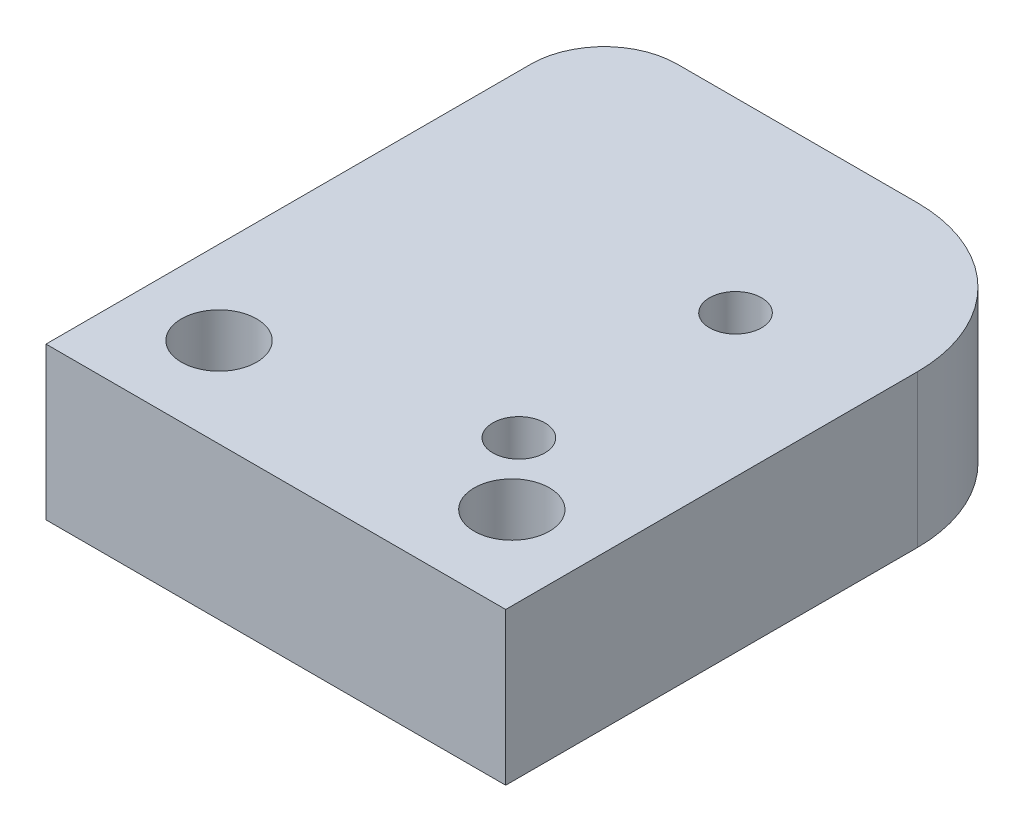
from build123d import *

# Parameters (mm, degrees)
SKETCH1_W                                           = 19.939
SKETCH1_H                                           = 24.2062
BOSS_EXTRUDE1_DEPTH                                 = 6.604
F_4_40_TAPPED_HOLE1_D                               = 2.2606
F_4_40_TAPPED_HOLE1_DEPTH                           = 6.604
CBORE_FOR_4_BINDING_HEAD_MACHINE_SCREW3_D           = 3.2639
CBORE_FOR_4_BINDING_HEAD_MACHINE_SCREW3_CBORE_D     = 4.9022
CBORE_FOR_4_BINDING_HEAD_MACHINE_SCREW3_CBORE_DEPTH = 1.7272
FILLET1_R                                           = 6.35
FILLET2_R                                           = 3.175


with BuildPart() as part:
    # Sketch1 → Boss-Extrude1 (new body)
    with BuildSketch(Plane(origin=(0, 0, 0), x_dir=(1, 0, 0), z_dir=(0, 1, 0))):
        with Locations((0, 12.1031)):
            Rectangle(SKETCH1_W, SKETCH1_H)
    extrude(amount=BOSS_EXTRUDE1_DEPTH)

    # #4-40 Tapped Hole1
    with Locations(Plane(origin=(0, 6.604, 0), x_dir=(1, 0, 0), z_dir=(0, 1, 0))):
        with Locations((3.81, 16.129), (3.81, 6.731)):
            Hole(F_4_40_TAPPED_HOLE1_D / 2, depth=F_4_40_TAPPED_HOLE1_DEPTH)

    # CBORE for #4 Binding Head Machine Screw3 (through all)
    with Locations(Plane(origin=(0, 0, 0), x_dir=(-1, 0, 0), z_dir=(0, -1, 0))):
        with Locations((6.35, 3.8862), (-6.35, 3.8862)):
            CounterBoreHole(CBORE_FOR_4_BINDING_HEAD_MACHINE_SCREW3_D / 2, CBORE_FOR_4_BINDING_HEAD_MACHINE_SCREW3_CBORE_D / 2, CBORE_FOR_4_BINDING_HEAD_MACHINE_SCREW3_CBORE_DEPTH)

    # Fillet1
    fillet1_edges = [part.edges().sort_by_distance(p)[0] for p in [
        (9.9695, 3.302, -24.2062),
    ]]
    fillet(fillet1_edges, radius=FILLET1_R)

    # Fillet2
    fillet2_edges = [part.edges().sort_by_distance(p)[0] for p in [
        (-9.9695, 3.302, -24.2062),
    ]]
    fillet(fillet2_edges, radius=FILLET2_R)


solid = part.part
